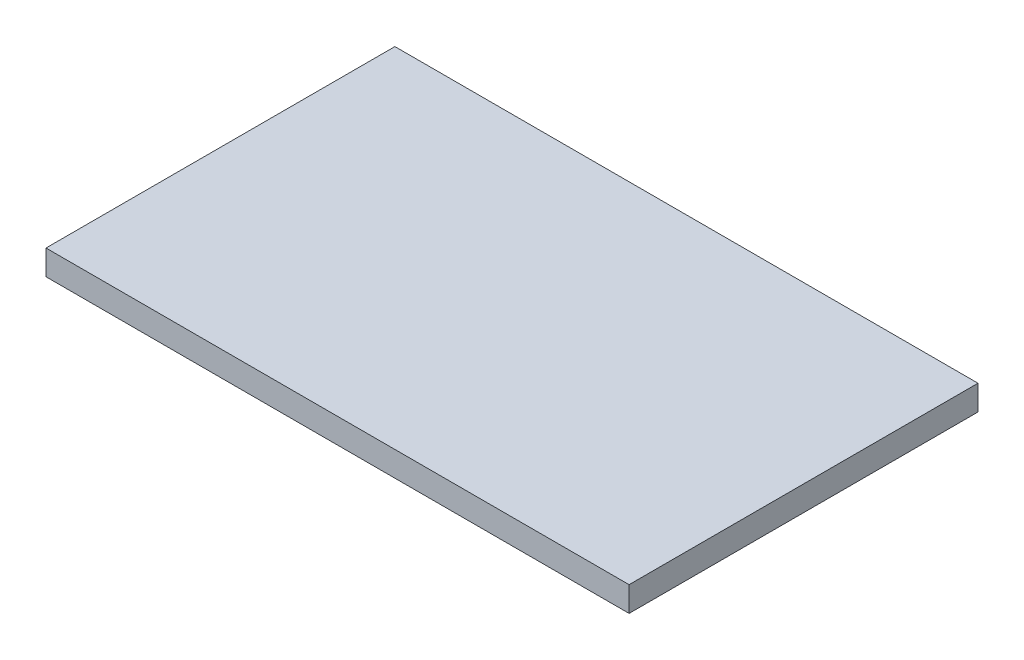
from build123d import *

# Parameters (mm, degrees)
SKETCH1_W           = 36.5
SKETCH1_H           = 21.84
BOSS_EXTRUDE1_DEPTH = 1.56


with BuildPart() as part:
    # Sketch1 → Boss-Extrude1 (new body)
    with BuildSketch(Plane(origin=(0, 0, 0), x_dir=(1, 0, 0), z_dir=(0, 1, 0))):
        with Locations((18.25, 10.92)):
            Rectangle(SKETCH1_W, SKETCH1_H)
    extrude(amount=BOSS_EXTRUDE1_DEPTH)


solid = part.part
